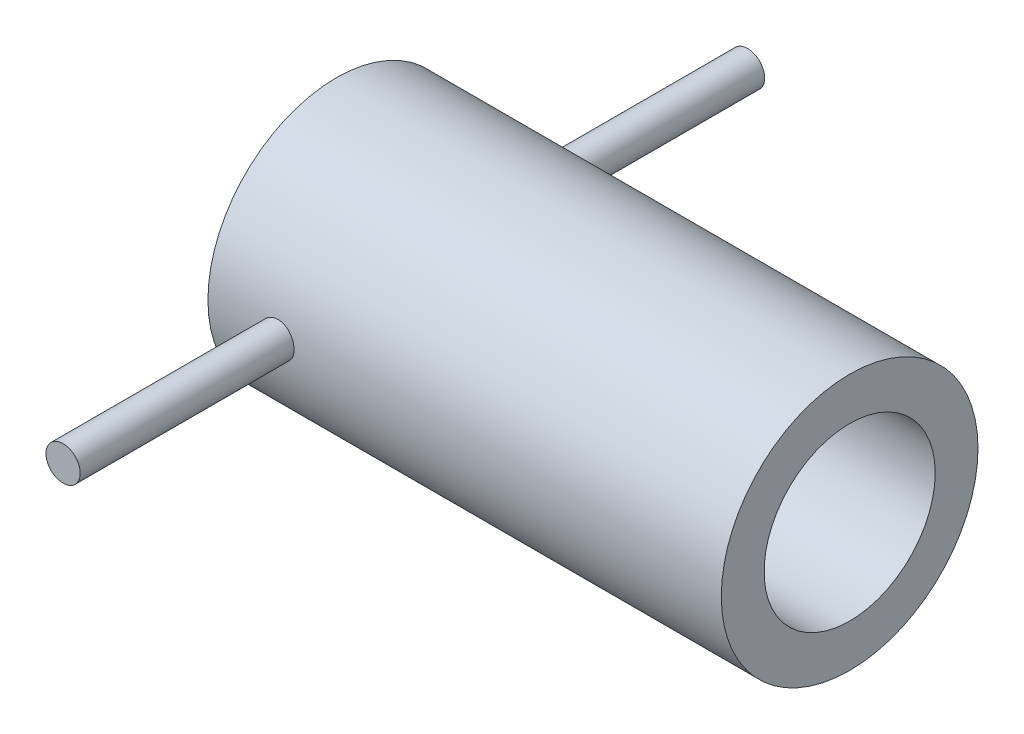
from build123d import *

# Parameters (mm, degrees)
SKETCH1_R           = 37.5
SKETCH1_R_2         = 25
BOSS_EXTRUDE1_DEPTH = 75
SKETCH2_R           = 5
BOSS_EXTRUDE2_DEPTH = 100


with BuildPart() as part:
    # Sketch1 → Boss-Extrude1 (new body, symmetric)
    with BuildSketch(Plane(origin=(0, 0, 0), x_dir=(0, 0, -1), z_dir=(1, 0, 0))):
        Circle(SKETCH1_R)
        Circle(SKETCH1_R_2, mode=Mode.SUBTRACT)
    extrude(amount=BOSS_EXTRUDE1_DEPTH, both=True)

    # Sketch2 → Boss-Extrude2 (add, symmetric)
    with BuildSketch(Plane.XY):
        with Locations((-54.825376389, 0)):
            Circle(SKETCH2_R)
    extrude(amount=BOSS_EXTRUDE2_DEPTH, both=True)


solid = part.part
